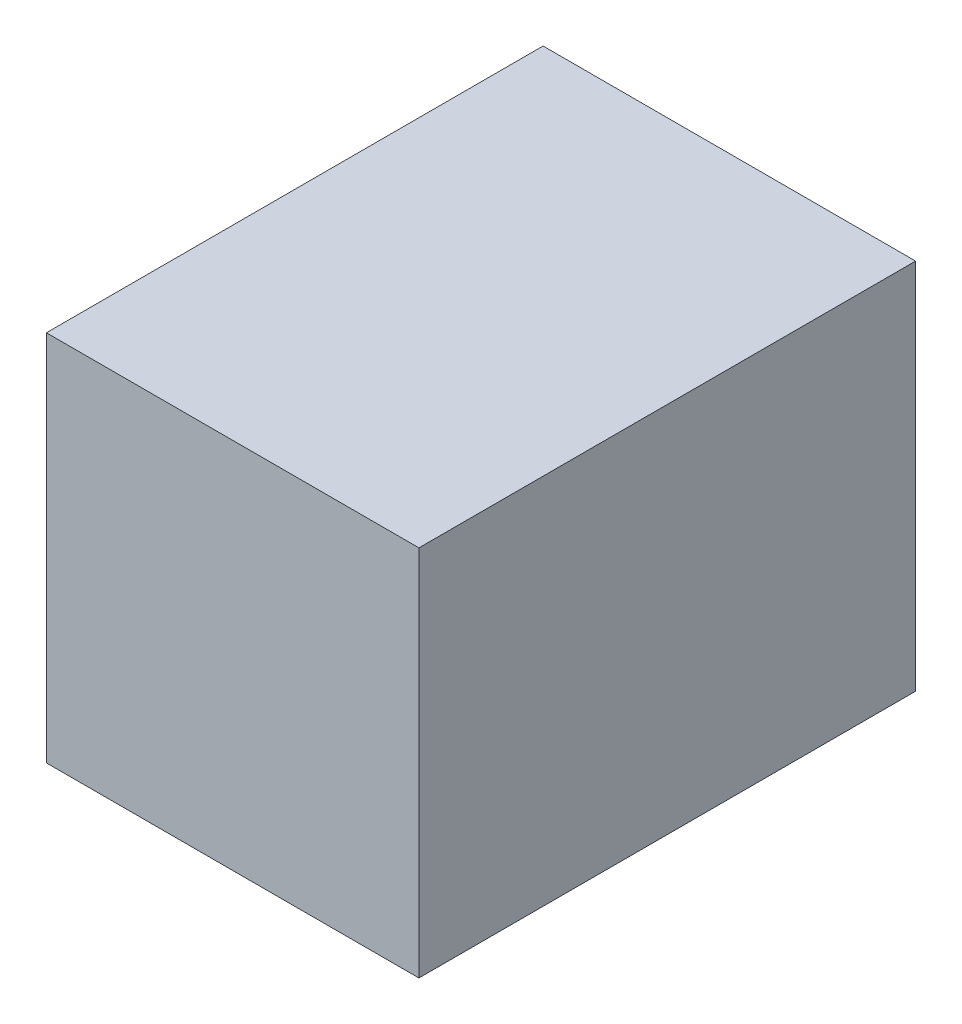
from build123d import *

# Parameters (mm, degrees)
SKETCH1_W           = 9.525
SKETCH1_H           = 9.525
BOSS_EXTRUDE1_DEPTH = 12.7


with BuildPart() as part:
    # Sketch1 → Boss-Extrude1 (new body)
    with BuildSketch(Plane.XY):
        with Locations((4.7625, 4.7625)):
            Rectangle(SKETCH1_W, SKETCH1_H)
    extrude(amount=BOSS_EXTRUDE1_DEPTH)


solid = part.part
